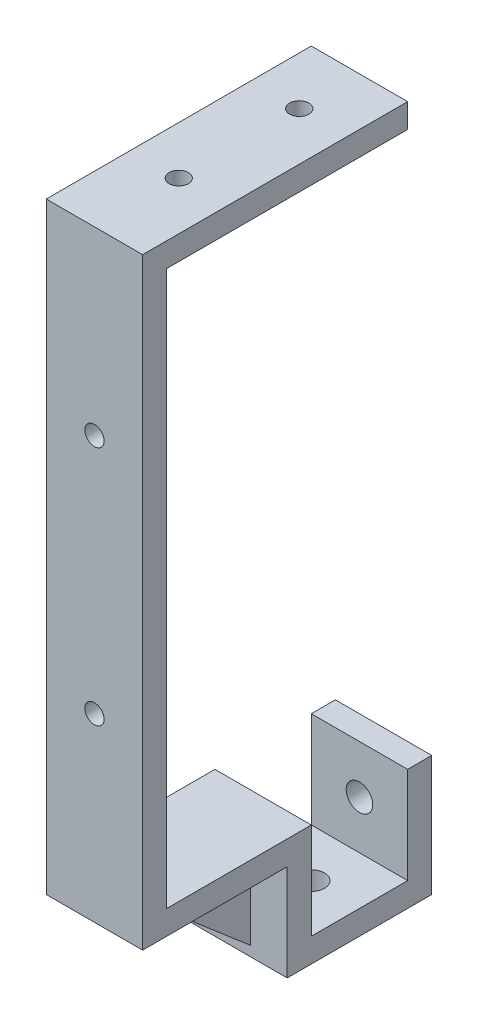
from build123d import *

# Parameters (mm, degrees)
SKETCH_1_W          = 20
SKETCH_1_H          = 145
EXTRUDE_1_DEPTH     = 5
SKETCH_3_W          = 20
SKETCH_3_H          = 5
EXTRUDE_2_DEPTH     = 50
SKETCH_4_W          = 20
SKETCH_4_H          = 5
EXTRUDE_3_DEPTH     = 30
SKETCH_5_W          = 20
SKETCH_5_H          = 20
CUT_EXTRUDE_1_DEPTH = 30
SKETCH_6_W          = 20
SKETCH_6_H          = 5
EXTRUDE_4_DEPTH     = 20
SKETCH_7_W          = 20
SKETCH_7_H          = 5
EXTRUDE_5_DEPTH     = 20
EXTRUDE_6_DEPTH     = 2.5
SKETCH_10_R         = 2
CUT_EXTRUDE_2_DEPTH = 5
SKETCH_11_R         = 2
CUT_EXTRUDE_3_DEPTH = 5
SKETCH_12_R         = 2.75
CUT_EXTRUDE_4_DEPTH = 5
SKETCH_13_W         = 20
SKETCH_13_H         = 5
EXTRUDE_7_DEPTH     = 5
SKETCH_14_W         = 20
SKETCH_14_H         = 5
EXTRUDE_8_DEPTH     = 20
SKETCH_15_R         = 2.75
CUT_EXTRUDE_5_DEPTH = 20


with BuildPart() as part:
    # 草图1 → 凸台-拉伸1 (new body)
    with BuildSketch(Plane.XY):
        with Locations((0.170940171, -57.628205128)):
            Rectangle(SKETCH_1_W, SKETCH_1_H)
    extrude(amount=-EXTRUDE_1_DEPTH)

    # 草图3 → 凸台-拉伸2 (add)
    with BuildSketch(Plane(origin=(0, 0, -5), x_dir=(-1, 0, 0), z_dir=(0, 0, -1))):
        with Locations((-0.170940171, 12.371794872)):
            Rectangle(SKETCH_3_W, SKETCH_3_H)
    extrude(amount=EXTRUDE_2_DEPTH)

    # 草图4 → 凸台-拉伸3 (add)
    with BuildSketch(Plane(origin=(0, 0, -5), x_dir=(-1, 0, 0), z_dir=(0, 0, -1))):
        with Locations((-0.170940171, -107.628205128)):
            Rectangle(SKETCH_4_W, SKETCH_4_H)
    extrude(amount=EXTRUDE_3_DEPTH)

    # 草图5 → 切除-拉伸1 (cut)
    with BuildSketch(Plane(origin=(0, 0, -5), x_dir=(-1, 0, 0), z_dir=(0, 0, -1))):
        with Locations((-0.170940171, -120.128205128)):
            Rectangle(SKETCH_5_W, SKETCH_5_H)
    extrude(amount=-CUT_EXTRUDE_1_DEPTH, mode=Mode.SUBTRACT)

    # 草图6 → 凸台-拉伸4 (add)
    with BuildSketch(Plane(origin=(0, -110.128205128, 0), x_dir=(-1, 0, 0), z_dir=(0, -1, 0))):
        with Locations((-0.170940171, 32.5)):
            Rectangle(SKETCH_6_W, SKETCH_6_H)
    extrude(amount=EXTRUDE_4_DEPTH)

    # 草图7 → 凸台-拉伸5 (add)
    with BuildSketch(Plane(origin=(0, 0, -35), x_dir=(-1, 0, 0), z_dir=(0, 0, -1))):
        with Locations((-0.170940171, -127.628205128)):
            Rectangle(SKETCH_7_W, SKETCH_7_H)
    extrude(amount=EXTRUDE_5_DEPTH)

    # 草图9 → 凸台-拉伸6 (add, symmetric)
    with BuildSketch(Plane(origin=(0.170940171, 0, 0), x_dir=(0, 0, -1), z_dir=(1, 0, 0))):
        Polygon((8.965273833, -110.036991646), (29.929169638, -127.991202337), (29.929169638, -110.036991646), align=None)
    extrude(amount=EXTRUDE_6_DEPTH, both=True)

    # 草图10 → 切除-拉伸2 (cut)
    with BuildSketch(Plane.XZ.offset(-9.871794872)):
        with Locations((0.170940171, -17.5)):
            Circle(SKETCH_10_R)
        with Locations((0.170940171, -42.5)):
            Circle(SKETCH_10_R)
    extrude(amount=-CUT_EXTRUDE_2_DEPTH, mode=Mode.SUBTRACT)

    # 草图11 → 切除-拉伸3 (cut)
    with BuildSketch(Plane(origin=(0, 0, -5), x_dir=(-1, 0, 0), z_dir=(0, 0, -1))):
        with Locations((-0.170940171, -22.628205128)):
            Circle(SKETCH_11_R)
        with Locations((-0.170940171, -72.628205128)):
            Circle(SKETCH_11_R)
    extrude(amount=-CUT_EXTRUDE_3_DEPTH, mode=Mode.SUBTRACT)

    # 草图12 → 切除-拉伸4 (cut)
    with BuildSketch(Plane(origin=(0, -125.128205128, 0), x_dir=(1, 0, 0), z_dir=(0, 1, 0))):
        with Locations((0.170940171, 45)):
            Circle(SKETCH_12_R)
    extrude(amount=-CUT_EXTRUDE_4_DEPTH, mode=Mode.SUBTRACT)

    # 草图13 → 凸台-拉伸7 (add)
    with BuildSketch(Plane(origin=(0, 0, -55), x_dir=(-1, 0, 0), z_dir=(0, 0, -1))):
        with Locations((-0.170940171, -127.628205128)):
            Rectangle(SKETCH_13_W, SKETCH_13_H)
    extrude(amount=EXTRUDE_7_DEPTH)

    # 草图14 → 凸台-拉伸8 (add)
    with BuildSketch(Plane(origin=(0, -125.128205128, 0), x_dir=(1, 0, 0), z_dir=(0, 1, 0))):
        with Locations((0.170940171, 57.5)):
            Rectangle(SKETCH_14_W, SKETCH_14_H)
    extrude(amount=EXTRUDE_8_DEPTH)

    # 草图15 → 切除-拉伸5 (cut)
    with BuildSketch(Plane.XY.offset(-55)):
        with Locations((0.170940171, -115.12820513)):
            Circle(SKETCH_15_R)
    extrude(amount=-CUT_EXTRUDE_5_DEPTH, mode=Mode.SUBTRACT)


solid = part.part
